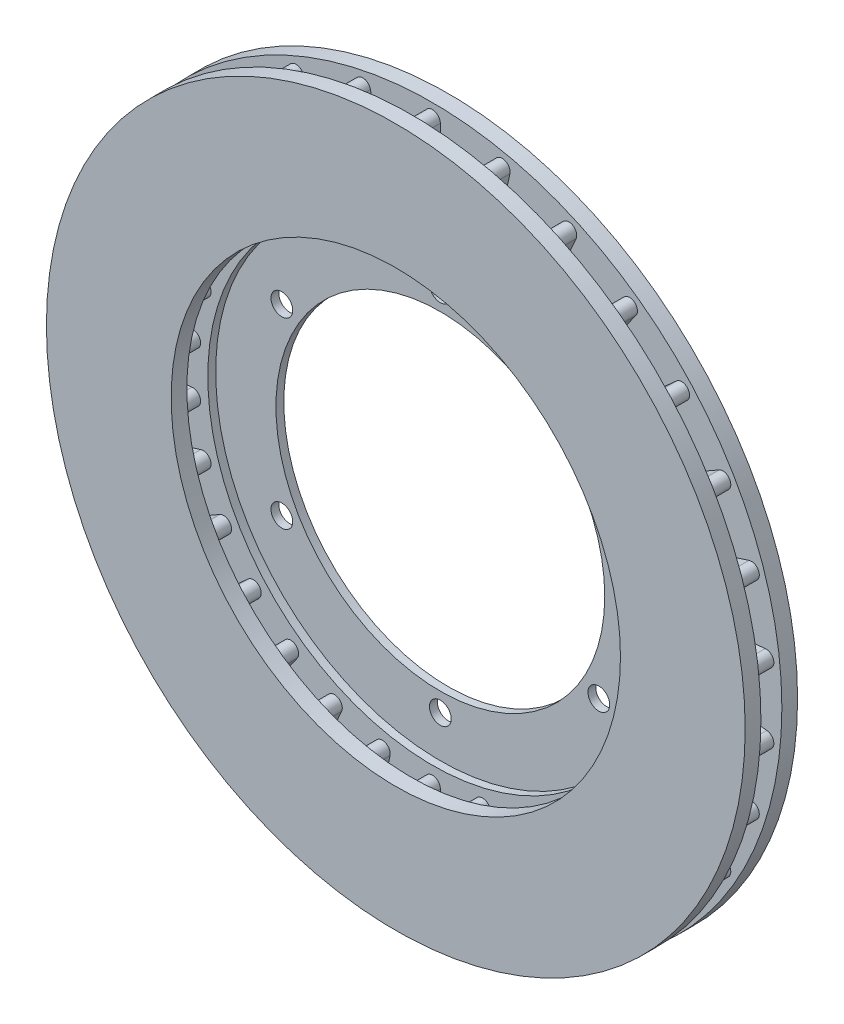
from build123d import *

# Parameters (mm, degrees)
SKETCH1_R               = 133.35
SKETCH1_R_2             = 85.75
EXTRUDE1_DEPTH          = 20
SKETCH2_R               = 85.75
SKETCH2_R_2             = 62.75
EXTRUDE2_DEPTH          = 3
SKETCH3_R               = 4.15
EXTRUDE7_DEPTH          = 11
SKETCH5_OUTSIDE_W       = 344.24
SKETCH5_OUTSIDE_H       = 344.24
CUT_EXTRUDE1_DEPTH      = 4
CUT_EXTRUDE1_DEPTH_BACK = 4


with BuildPart() as part:
    # Sketch1 → Extrude1 (new body)
    with BuildSketch(Plane.XY):
        Circle(SKETCH1_R)
        Circle(SKETCH1_R_2, mode=Mode.SUBTRACT)
    extrude(amount=EXTRUDE1_DEPTH)

    # Sketch2 → Extrude2 (add)
    with BuildSketch(Plane.XY):
        Circle(SKETCH2_R)
        Circle(SKETCH2_R_2, mode=Mode.SUBTRACT)
    extrude(amount=EXTRUDE2_DEPTH)

    # Sketch3 → Extrude7 (cut)
    with BuildSketch(Plane.XY):
        with Locations((0, 69.85)):
            Circle(SKETCH3_R)
        with Locations((60.491874454, 34.925)):
            Circle(SKETCH3_R)
        with Locations((60.491874454, -34.925)):
            Circle(SKETCH3_R)
        with Locations((0, -69.85)):
            Circle(SKETCH3_R)
        with Locations((-60.491874454, -34.925)):
            Circle(SKETCH3_R)
        with Locations((-60.491874454, 34.925)):
            Circle(SKETCH3_R)
    extrude(amount=EXTRUDE7_DEPTH, mode=Mode.SUBTRACT)

    # Sketch5 outside → Cut-Extrude1 (cut, two sides)
    with BuildSketch(Plane.XY.offset(10)) as cut_extrude1_sk:
        Rectangle(SKETCH5_OUTSIDE_W, SKETCH5_OUTSIDE_H)
        with BuildLine():
            Line((3, 128), (3, 92))
            ThreePointArc((3, 92), (0, 89), (-3, 92))
            Line((-3, 92), (-3, 128))
            ThreePointArc((-3, 128), (0, 131), (3, 128))
        make_face(mode=Mode.SUBTRACT)
        with BuildLine():
            Line((29.547139227, 124.579157821), (22.062318357, 89.365844195))
            ThreePointArc((22.062318357, 89.365844195), (18.504140483, 87.055136465), (16.193432753, 90.61331434))
            Line((16.193432753, 90.61331434), (23.678253622, 125.826627966))
            ThreePointArc((23.678253622, 125.826627966), (27.236431497, 128.137335696), (29.547139227, 124.579157821))
        make_face(mode=Mode.SUBTRACT)
        with BuildLine():
            Line((54.802926687, 115.713608649), (40.160407536, 82.825972174))
            ThreePointArc((40.160407536, 82.825972174), (36.199561234, 81.30554573), (34.67913479, 85.266392032))
            Line((34.67913479, 85.266392032), (49.321653941, 118.154028507))
            ThreePointArc((49.321653941, 118.154028507), (53.282500243, 119.674454951), (54.802926687, 115.713608649))
        make_face(mode=Mode.SUBTRACT)
        with BuildLine():
            Line((77.663563277, 101.790819523), (56.503294194, 72.666207726))
            ThreePointArc((56.503294194, 72.666207726), (52.312887454, 72.002512499), (51.649192228, 76.192919239))
            Line((51.649192228, 76.192919239), (72.80946131, 105.317531037))
            ThreePointArc((72.80946131, 105.317531037), (76.99986805, 105.981226263), (77.663563277, 101.790819523))
        make_face(mode=Mode.SUBTRACT)
        with BuildLine():
            Line((97.12992948, 83.419283138), (70.376715763, 59.330581309))
            ThreePointArc((70.376715763, 59.330581309), (66.139889467, 59.552623966), (66.361932125, 63.789450261))
            Line((66.361932125, 63.789450261), (93.115145842, 87.87815209))
            ThreePointArc((93.115145842, 87.87815209), (97.351972138, 87.656109433), (97.12992948, 83.419283138))
        make_face(mode=Mode.SUBTRACT)
        with BuildLine():
            Line((112.351251684, 61.401923789), (81.174337148, 43.401923789))
            ThreePointArc((81.174337148, 43.401923789), (77.076260937, 44.5), (78.174337148, 48.598076211))
            Line((78.174337148, 48.598076211), (109.351251684, 66.598076211))
            ThreePointArc((109.351251684, 66.598076211), (113.449327896, 65.5), (112.351251684, 61.401923789))
        make_face(mode=Mode.SUBTRACT)
        with BuildLine():
            Line((122.662285069, 36.701005731), (88.424250482, 25.576393934))
            ThreePointArc((88.424250482, 25.576393934), (84.64402995, 27.502512499), (86.570148516, 31.282733031))
            Line((86.570148516, 31.282733031), (120.808183103, 42.407344829))
            ThreePointArc((120.808183103, 42.407344829), (124.588403635, 40.481226263), (122.662285069, 36.701005731))
        make_face(mode=Mode.SUBTRACT)
        with BuildLine():
            Line((127.612387997, 10.396077612), (91.809599764, 6.633052935))
            ThreePointArc((91.809599764, 6.633052935), (88.512448688, 9.303033231), (91.182428984, 12.600184307))
            Line((91.182428984, 12.600184307), (126.985217217, 16.363208984))
            ThreePointArc((126.985217217, 16.363208984), (130.282368293, 13.693228688), (127.612387997, 10.396077612))
        make_face(mode=Mode.SUBTRACT)
        with BuildLine():
            Line((126.985217217, -16.363208984), (91.182428984, -12.600184307))
            ThreePointArc((91.182428984, -12.600184307), (88.512448688, -9.303033231), (91.809599764, -6.633052935))
            Line((91.809599764, -6.633052935), (127.612387997, -10.396077612))
            ThreePointArc((127.612387997, -10.396077612), (130.282368293, -13.693228688), (126.985217217, -16.363208984))
        make_face(mode=Mode.SUBTRACT)
        with BuildLine():
            Line((120.808183103, -42.407344829), (86.570148516, -31.282733031))
            ThreePointArc((86.570148516, -31.282733031), (84.64402995, -27.502512499), (88.424250482, -25.576393934))
            Line((88.424250482, -25.576393934), (122.662285069, -36.701005731))
            ThreePointArc((122.662285069, -36.701005731), (124.588403635, -40.481226263), (120.808183103, -42.407344829))
        make_face(mode=Mode.SUBTRACT)
        with BuildLine():
            Line((109.351251684, -66.598076211), (78.174337148, -48.598076211))
            ThreePointArc((78.174337148, -48.598076211), (77.076260937, -44.5), (81.174337148, -43.401923789))
            Line((81.174337148, -43.401923789), (112.351251684, -61.401923789))
            ThreePointArc((112.351251684, -61.401923789), (113.449327896, -65.5), (109.351251684, -66.598076211))
        make_face(mode=Mode.SUBTRACT)
        with BuildLine():
            Line((93.115145842, -87.87815209), (66.361932125, -63.789450261))
            ThreePointArc((66.361932125, -63.789450261), (66.139889467, -59.552623966), (70.376715763, -59.330581309))
            Line((70.376715763, -59.330581309), (97.12992948, -83.419283138))
            ThreePointArc((97.12992948, -83.419283138), (97.351972138, -87.656109433), (93.115145842, -87.87815209))
        make_face(mode=Mode.SUBTRACT)
        with BuildLine():
            Line((72.80946131, -105.317531037), (51.649192228, -76.192919239))
            ThreePointArc((51.649192228, -76.192919239), (52.312887454, -72.002512499), (56.503294194, -72.666207726))
            Line((56.503294194, -72.666207726), (77.663563277, -101.790819523))
            ThreePointArc((77.663563277, -101.790819523), (76.99986805, -105.981226263), (72.80946131, -105.317531037))
        make_face(mode=Mode.SUBTRACT)
        with BuildLine():
            Line((49.321653941, -118.154028507), (34.67913479, -85.266392032))
            ThreePointArc((34.67913479, -85.266392032), (36.199561234, -81.30554573), (40.160407536, -82.825972174))
            Line((40.160407536, -82.825972174), (54.802926687, -115.713608649))
            ThreePointArc((54.802926687, -115.713608649), (53.282500243, -119.674454951), (49.321653941, -118.154028507))
        make_face(mode=Mode.SUBTRACT)
        with BuildLine():
            Line((23.678253622, -125.826627966), (16.193432753, -90.61331434))
            ThreePointArc((16.193432753, -90.61331434), (18.504140483, -87.055136465), (22.062318357, -89.365844195))
            Line((22.062318357, -89.365844195), (29.547139227, -124.579157821))
            ThreePointArc((29.547139227, -124.579157821), (27.236431497, -128.137335696), (23.678253622, -125.826627966))
        make_face(mode=Mode.SUBTRACT)
        with BuildLine():
            Line((-3, -128), (-3, -92))
            ThreePointArc((-3, -92), (0, -89), (3, -92))
            Line((3, -92), (3, -128))
            ThreePointArc((3, -128), (0, -131), (-3, -128))
        make_face(mode=Mode.SUBTRACT)
        with BuildLine():
            Line((-29.547139227, -124.579157821), (-22.062318357, -89.365844195))
            ThreePointArc((-22.062318357, -89.365844195), (-18.504140483, -87.055136465), (-16.193432753, -90.61331434))
            Line((-16.193432753, -90.61331434), (-23.678253622, -125.826627966))
            ThreePointArc((-23.678253622, -125.826627966), (-27.236431497, -128.137335696), (-29.547139227, -124.579157821))
        make_face(mode=Mode.SUBTRACT)
        with BuildLine():
            Line((-54.802926687, -115.713608649), (-40.160407536, -82.825972174))
            ThreePointArc((-40.160407536, -82.825972174), (-36.199561234, -81.30554573), (-34.67913479, -85.266392032))
            Line((-34.67913479, -85.266392032), (-49.321653941, -118.154028507))
            ThreePointArc((-49.321653941, -118.154028507), (-53.282500243, -119.674454951), (-54.802926687, -115.713608649))
        make_face(mode=Mode.SUBTRACT)
        with BuildLine():
            Line((-77.663563277, -101.790819523), (-56.503294194, -72.666207726))
            ThreePointArc((-56.503294194, -72.666207726), (-52.312887454, -72.002512499), (-51.649192228, -76.192919239))
            Line((-51.649192228, -76.192919239), (-72.80946131, -105.317531037))
            ThreePointArc((-72.80946131, -105.317531037), (-76.99986805, -105.981226263), (-77.663563277, -101.790819523))
        make_face(mode=Mode.SUBTRACT)
        with BuildLine():
            Line((-97.12992948, -83.419283138), (-70.376715763, -59.330581309))
            ThreePointArc((-70.376715763, -59.330581309), (-66.139889467, -59.552623966), (-66.361932125, -63.789450261))
            Line((-66.361932125, -63.789450261), (-93.115145842, -87.87815209))
            ThreePointArc((-93.115145842, -87.87815209), (-97.351972138, -87.656109433), (-97.12992948, -83.419283138))
        make_face(mode=Mode.SUBTRACT)
        with BuildLine():
            Line((-112.351251684, -61.401923789), (-81.174337148, -43.401923789))
            ThreePointArc((-81.174337148, -43.401923789), (-77.076260937, -44.5), (-78.174337148, -48.598076211))
            Line((-78.174337148, -48.598076211), (-109.351251684, -66.598076211))
            ThreePointArc((-109.351251684, -66.598076211), (-113.449327896, -65.5), (-112.351251684, -61.401923789))
        make_face(mode=Mode.SUBTRACT)
        with BuildLine():
            Line((-122.662285069, -36.701005731), (-88.424250482, -25.576393934))
            ThreePointArc((-88.424250482, -25.576393934), (-84.64402995, -27.502512499), (-86.570148516, -31.282733031))
            Line((-86.570148516, -31.282733031), (-120.808183103, -42.407344829))
            ThreePointArc((-120.808183103, -42.407344829), (-124.588403635, -40.481226263), (-122.662285069, -36.701005731))
        make_face(mode=Mode.SUBTRACT)
        with BuildLine():
            Line((-127.612387997, -10.396077612), (-91.809599764, -6.633052935))
            ThreePointArc((-91.809599764, -6.633052935), (-88.512448688, -9.303033231), (-91.182428984, -12.600184307))
            Line((-91.182428984, -12.600184307), (-126.985217217, -16.363208984))
            ThreePointArc((-126.985217217, -16.363208984), (-130.282368293, -13.693228688), (-127.612387997, -10.396077612))
        make_face(mode=Mode.SUBTRACT)
        with BuildLine():
            Line((-126.985217217, 16.363208984), (-91.182428984, 12.600184307))
            ThreePointArc((-91.182428984, 12.600184307), (-88.512448688, 9.303033231), (-91.809599764, 6.633052935))
            Line((-91.809599764, 6.633052935), (-127.612387997, 10.396077612))
            ThreePointArc((-127.612387997, 10.396077612), (-130.282368293, 13.693228688), (-126.985217217, 16.363208984))
        make_face(mode=Mode.SUBTRACT)
        with BuildLine():
            Line((-120.808183103, 42.407344829), (-86.570148516, 31.282733031))
            ThreePointArc((-86.570148516, 31.282733031), (-84.64402995, 27.502512499), (-88.424250482, 25.576393934))
            Line((-88.424250482, 25.576393934), (-122.662285069, 36.701005731))
            ThreePointArc((-122.662285069, 36.701005731), (-124.588403635, 40.481226263), (-120.808183103, 42.407344829))
        make_face(mode=Mode.SUBTRACT)
        with BuildLine():
            Line((-109.351251684, 66.598076211), (-78.174337148, 48.598076211))
            ThreePointArc((-78.174337148, 48.598076211), (-77.076260937, 44.5), (-81.174337148, 43.401923789))
            Line((-81.174337148, 43.401923789), (-112.351251684, 61.401923789))
            ThreePointArc((-112.351251684, 61.401923789), (-113.449327896, 65.5), (-109.351251684, 66.598076211))
        make_face(mode=Mode.SUBTRACT)
        with BuildLine():
            Line((-93.115145842, 87.87815209), (-66.361932125, 63.789450261))
            ThreePointArc((-66.361932125, 63.789450261), (-66.139889467, 59.552623966), (-70.376715763, 59.330581309))
            Line((-70.376715763, 59.330581309), (-97.12992948, 83.419283138))
            ThreePointArc((-97.12992948, 83.419283138), (-97.351972138, 87.656109433), (-93.115145842, 87.87815209))
        make_face(mode=Mode.SUBTRACT)
        with BuildLine():
            Line((-72.80946131, 105.317531037), (-51.649192228, 76.192919239))
            ThreePointArc((-51.649192228, 76.192919239), (-52.312887454, 72.002512499), (-56.503294194, 72.666207726))
            Line((-56.503294194, 72.666207726), (-77.663563277, 101.790819523))
            ThreePointArc((-77.663563277, 101.790819523), (-76.99986805, 105.981226263), (-72.80946131, 105.317531037))
        make_face(mode=Mode.SUBTRACT)
        with BuildLine():
            Line((-49.321653941, 118.154028507), (-34.67913479, 85.266392032))
            ThreePointArc((-34.67913479, 85.266392032), (-36.199561234, 81.30554573), (-40.160407536, 82.825972174))
            Line((-40.160407536, 82.825972174), (-54.802926687, 115.713608649))
            ThreePointArc((-54.802926687, 115.713608649), (-53.282500243, 119.674454951), (-49.321653941, 118.154028507))
        make_face(mode=Mode.SUBTRACT)
        with BuildLine():
            Line((-23.678253622, 125.826627966), (-16.193432753, 90.61331434))
            ThreePointArc((-16.193432753, 90.61331434), (-18.504140483, 87.055136465), (-22.062318357, 89.365844195))
            Line((-22.062318357, 89.365844195), (-29.547139227, 124.579157821))
            ThreePointArc((-29.547139227, 124.579157821), (-27.236431497, 128.137335696), (-23.678253622, 125.826627966))
        make_face(mode=Mode.SUBTRACT)
    extrude(amount=CUT_EXTRUDE1_DEPTH, mode=Mode.SUBTRACT)
    extrude(cut_extrude1_sk.sketch, amount=-CUT_EXTRUDE1_DEPTH_BACK, mode=Mode.SUBTRACT)


solid = part.part
